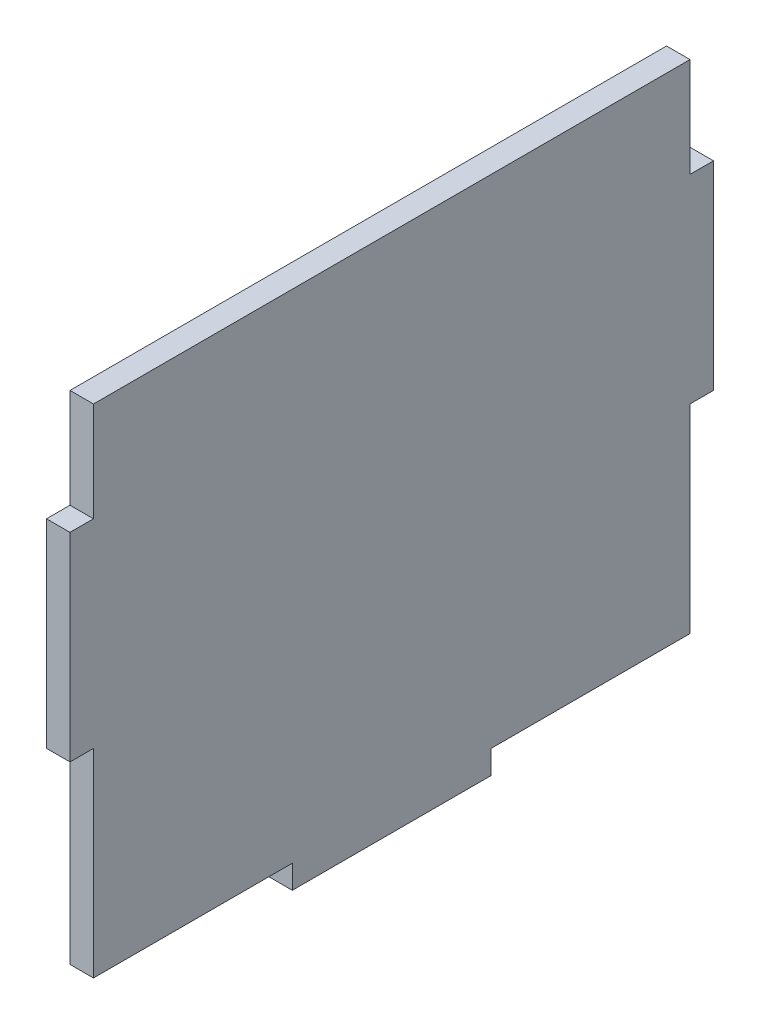
from build123d import *

# Parameters (mm, degrees)
BOSS_EXTRUDE1_DEPTH = 3


with BuildPart() as part:
    # Sketch1 → Boss-Extrude1 (new body)
    with BuildSketch(Plane(origin=(0, 0, 0), x_dir=(0, 0, -1), z_dir=(1, 0, 0))):
        Polygon((-38.1, -17.2847), (-38.1, -20.8153), (-38.1, -31.75), (-12.7, -31.75), (-12.7, -34.75), (12.7, -34.75), (12.7, -31.75), (38.1, -31.75), (38.1, -20.8153), (38.1, -17.2847), (38.1, -6.35), (41.1, -6.35), (41.1, 19.05), (38.1, 19.05), (38.1, 31.75), (-38.1, 31.75), (-38.1, 19.05), (-41.1, 19.05), (-41.1, -6.35), (-38.1, -6.35), align=None)
    extrude(amount=BOSS_EXTRUDE1_DEPTH)


solid = part.part
